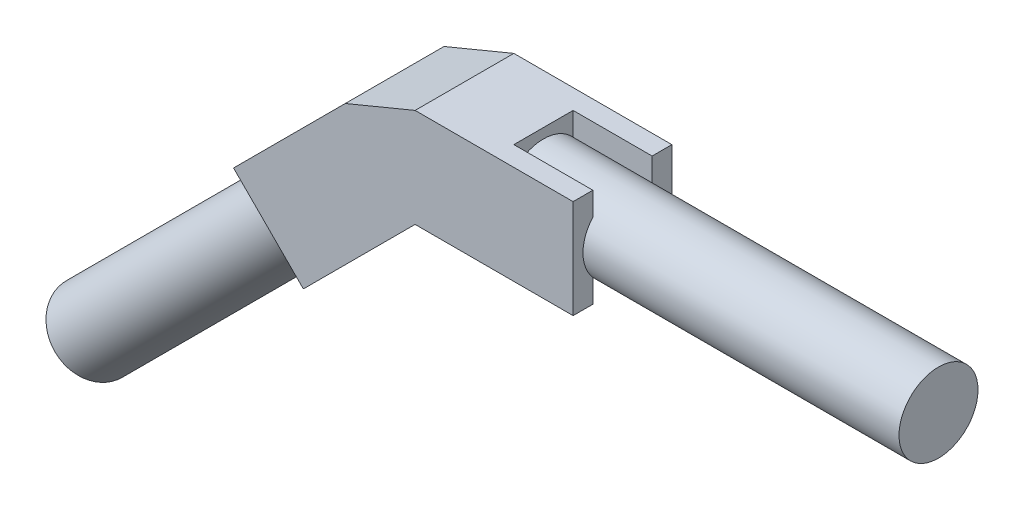
from build123d import *

# Parameters (mm, degrees)
SKETCH1_R           = 12.7
BOSS_EXTRUDE1_DEPTH = 127
SKETCH2_W           = 31.75
SKETCH2_H           = 31.75
BOSS_EXTRUDE2_DEPTH = 25.4
SKETCH3_W           = 25.4
SKETCH3_H           = 31.75
BOSS_EXTRUDE3_DEPTH = 6.35
SKETCH4_W           = 25.4
SKETCH4_H           = 31.75
BOSS_EXTRUDE4_DEPTH = 6.35
SKETCH9_W           = 31.75
SKETCH9_H           = 31.75
BOSS_EXTRUDE5_DEPTH = 25.4
SKETCH11_R          = 12.7
BOSS_EXTRUDE6_DEPTH = 127
BOSS_EXTRUDE7_DEPTH = 6.35
BOSS_EXTRUDE8_DEPTH = 6.35
BOSS_EXTRUDE9_DEPTH = 31.75


with BuildPart() as part:
    # Sketch1 → Boss-Extrude1 (new body)
    with BuildSketch(Plane(origin=(0, 0, 0), x_dir=(0, 0, -1), z_dir=(1, 0, 0))):
        Circle(SKETCH1_R)
    extrude(amount=BOSS_EXTRUDE1_DEPTH)

    # Sketch2 → Boss-Extrude2 (add)
    with BuildSketch(Plane.ZY):
        Rectangle(SKETCH2_W, SKETCH2_H)
    extrude(amount=BOSS_EXTRUDE2_DEPTH)

    # Sketch3 → Boss-Extrude3 (add)
    with BuildSketch(Plane.XY.offset(15.875)):
        with Locations((12.7, 0)):
            Rectangle(SKETCH3_W, SKETCH3_H)
    extrude(amount=-BOSS_EXTRUDE3_DEPTH)

    # Sketch4 → Boss-Extrude4 (add)
    with BuildSketch(Plane(origin=(0, 0, -15.875), x_dir=(-1, 0, 0), z_dir=(0, 0, -1))):
        with Locations((-12.7, 0)):
            Rectangle(SKETCH4_W, SKETCH4_H)
    extrude(amount=-BOSS_EXTRUDE4_DEPTH)



with BuildPart() as body_2:
    # Sketch9 → Boss-Extrude5 (new body)
    with BuildSketch(Plane(origin=(-20.6375, -20.6375, 0), x_dir=(0, 0, 1), z_dir=(-0.707106781, -0.707106781, 0))):
        with Locations((0, 22.610192091)):
            Rectangle(SKETCH9_W, SKETCH9_H)
    extrude(amount=BOSS_EXTRUDE5_DEPTH)

    # Sketch11 → Boss-Extrude6 (add)
    with BuildSketch(Plane(origin=(-38.598012242, -38.598012242, 0), x_dir=(0, 0, 1), z_dir=(-0.707106781, -0.707106781, 0))):
        with Locations((0, 22.610192091)):
            Circle(SKETCH11_R)
    extrude(amount=BOSS_EXTRUDE6_DEPTH)

    # Sketch13 → Boss-Extrude7 (add)
    with BuildSketch(Plane.XY.offset(15.875)):
        Polygon((-43.360512242, -33.835512242), (-61.321024484, -51.796024484), (-83.771664787, -29.345384182), (-65.811152545, -11.384871939), align=None)
    extrude(amount=-BOSS_EXTRUDE7_DEPTH)

    # Sketch14 → Boss-Extrude8 (add)
    with BuildSketch(Plane(origin=(0, 0, -15.875), x_dir=(-1, 0, 0), z_dir=(0, 0, -1))):
        Polygon((65.811152545, -11.384871939), (83.771664787, -29.345384182), (61.321024484, -51.796024484), (43.360512242, -33.835512242), align=None)
    extrude(amount=-BOSS_EXTRUDE8_DEPTH)


with BuildPart() as part_1:
    add(part.part)

    add(body_2.part)  # Boss-Extrude9 merges body 2
    # Sketch15 → Boss-Extrude9 (add)
    with BuildSketch(Plane(origin=(0, 0, -15.875), x_dir=(-1, 0, 0), z_dir=(0, 0, -1))):
        Polygon((25.4, 15.875), (47.850640303, 6.575640303), (25.4, -15.875), align=None)
    extrude(amount=-BOSS_EXTRUDE9_DEPTH)


solid = part_1.part
